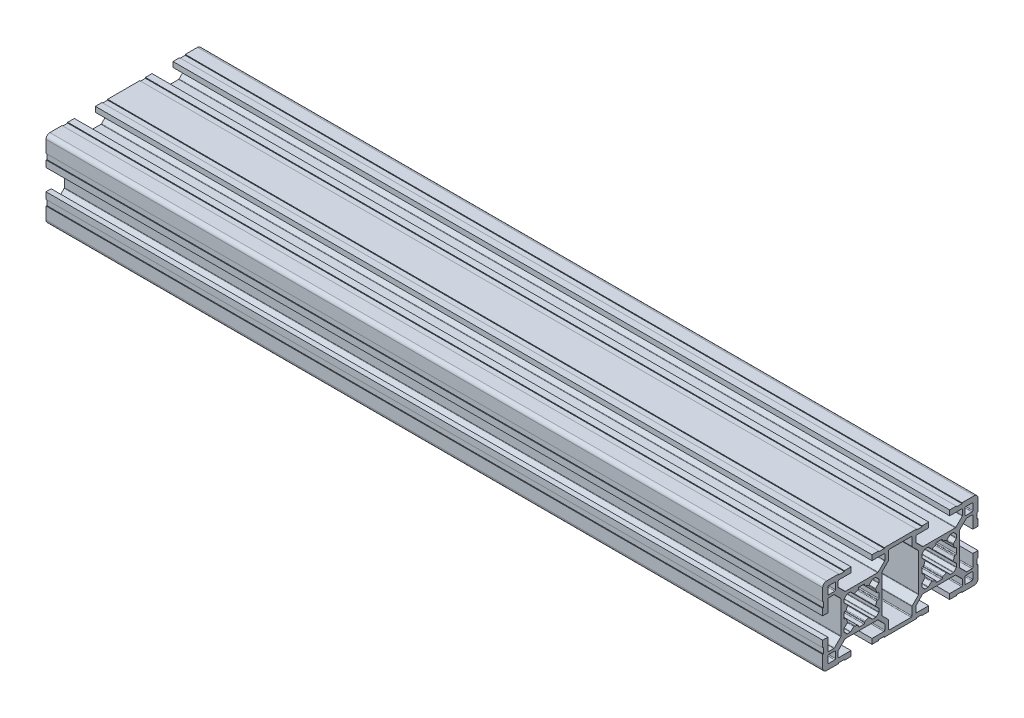
from build123d import *

# Parameters (mm, degrees)
RETANGULAR_PF30_02_PERFIL_3060_B_SICO_DEPTH = 300


with BuildPart() as part:
    # Sketch11 → Retangular PF30-02 - PERFIL 3060 BÁSICO(1) (new body)
    with BuildSketch(Plane.YZ.offset(-150)):
        with BuildLine():
            Line((-10.467761979, 23.914900409), (-7.987862303, 21.435000909))
            ThreePointArc((-7.987862303, 21.435000909), (-7.922830472, 21.337673902), (-7.89999433, 21.222868867))
            Line((-7.89999433, 21.222868867), (-7.89999433, 8.78267257))
            ThreePointArc((-7.89999433, 8.78267257), (-7.922830472, 8.667867535), (-7.987862303, 8.570540528))
            Line((-7.987862303, 8.570540528), (-10.467761979, 6.090641028))
            ThreePointArc((-10.467761979, 6.090641028), (-10.565088981, 6.025609208), (-10.679894006, 6.00277307))
            Line((-10.679894006, 6.00277307), (-12.699995366, 6.00277307))
            ThreePointArc((-12.699995366, 6.00277307), (-12.9121274, 6.090641035), (-12.999995366, 6.30277307))
            Line((-12.999995366, 6.30277307), (-12.999995366, 10.952772018))
            Line((-12.999995366, 10.952772018), (-14.999995923, 10.952772018))
            Line((-14.999995923, 10.952772018), (-14.999995923, 8.402773901))
            Line((-14.999995923, 8.402773901), (-14.699995922, 8.402773901))
            Line((-14.699995922, 8.402773901), (-14.699995922, 6.2027739))
            Line((-14.699995922, 6.2027739), (-14.999995923, 6.2027739))
            Line((-14.999995923, 6.2027739), (-14.999995923, -6.197224309))
            Line((-14.999995923, -6.197224309), (-14.699995922, -6.197224309))
            Line((-14.699995922, -6.197224309), (-14.699995922, -8.397224309))
            Line((-14.699995922, -8.397224309), (-14.999995923, -8.397224309))
            Line((-14.999995923, -8.397224309), (-14.999995923, -10.947222427))
            Line((-14.999995923, -10.947222427), (-12.999995366, -10.947222427))
            Line((-12.999995366, -10.947222427), (-12.999995366, -6.297223478))
            ThreePointArc((-12.999995366, -6.297223478), (-12.9121274, -6.085091444), (-12.699995366, -5.997223478))
            Line((-12.699995366, -5.997223478), (-10.679894006, -5.997223478))
            ThreePointArc((-10.679894006, -5.997223478), (-10.565088981, -6.020059616), (-10.467761979, -6.085091436))
            Line((-10.467761979, -6.085091436), (-7.987862303, -8.564990936))
            ThreePointArc((-7.987862303, -8.564990936), (-7.922830472, -8.662317943), (-7.89999433, -8.777122978))
            Line((-7.89999433, -8.777122978), (-7.89999433, -21.217319276))
            ThreePointArc((-7.89999433, -21.217319276), (-7.922830472, -21.33212431), (-7.987862303, -21.429451318))
            Line((-7.987862303, -21.429451318), (-10.467761979, -23.909350818))
            ThreePointArc((-10.467761979, -23.909350818), (-10.565088981, -23.974382637), (-10.679894006, -23.997218776))
            Line((-10.679894006, -23.997218776), (-12.699995366, -23.997218776))
            ThreePointArc((-12.699995366, -23.997218776), (-12.9121274, -23.90935081), (-12.999995366, -23.697218776))
            Line((-12.999995366, -23.697218776), (-12.999995366, -19.047219827))
            Line((-12.999995366, -19.047219827), (-14.999995923, -19.047219827))
            Line((-14.999995923, -19.047219827), (-14.999995923, -21.597217945))
            Line((-14.999995923, -21.597217945), (-14.699995922, -21.597217945))
            Line((-14.699995922, -21.597217945), (-14.699995922, -23.797217945))
            Line((-14.699995922, -23.797217945), (-14.999995923, -23.797217945))
            Line((-14.999995923, -23.797217945), (-14.999995923, -28.497216952))
            ThreePointArc((-14.999995923, -28.497216952), (-14.560656066, -29.557877193), (-13.499995825, -29.997217049))
            Line((-13.499995825, -29.997217049), (-8.799996802, -29.997217049))
            Line((-8.799996802, -29.997217049), (-8.799996802, -29.697217049))
            Line((-8.799996802, -29.697217049), (-6.599996802, -29.697217049))
            Line((-6.599996802, -29.697217049), (-6.599996802, -29.99721705))
            Line((-6.599996802, -29.99721705), (-4.0499987, -29.99721705))
            Line((-4.0499987, -29.99721705), (-4.0499987, -27.997216493))
            Line((-4.0499987, -27.997216493), (-8.699997649, -27.997216493))
            ThreePointArc((-8.699997649, -27.997216493), (-8.912129683, -27.909348527), (-8.999997649, -27.697216493))
            Line((-8.999997649, -27.697216493), (-8.999997649, -25.677115133))
            ThreePointArc((-8.999997649, -25.677115133), (-8.977161511, -25.562310108), (-8.912129691, -25.464983106))
            Line((-8.912129691, -25.464983106), (-6.432230191, -22.98508343))
            ThreePointArc((-6.432230191, -22.98508343), (-6.334903184, -22.920051599), (-6.220098149, -22.897215457))
            Line((-6.220098149, -22.897215457), (6.220098149, -22.897215457))
            ThreePointArc((6.220098149, -22.897215457), (6.334903184, -22.920051599), (6.432230191, -22.98508343))
            Line((6.432230191, -22.98508343), (8.912129691, -25.464983106))
            ThreePointArc((8.912129691, -25.464983106), (8.977161511, -25.562310108), (8.999997649, -25.677115133))
            Line((8.999997649, -25.677115133), (8.999997649, -27.697216493))
            ThreePointArc((8.999997649, -27.697216493), (8.912129683, -27.909348527), (8.699997649, -27.997216493))
            Line((8.699997649, -27.997216493), (4.0499987, -27.997216493))
            Line((4.0499987, -27.997216493), (4.0499987, -29.99721705))
            Line((4.0499987, -29.99721705), (6.599996802, -29.99721705))
            Line((6.599996802, -29.99721705), (6.599996802, -29.697217049))
            Line((6.599996802, -29.697217049), (8.799996802, -29.697217049))
            Line((8.799996802, -29.697217049), (8.799996802, -29.997217049))
            Line((8.799996802, -29.997217049), (13.499995825, -29.997217049))
            ThreePointArc((13.499995825, -29.997217049), (14.560656066, -29.557877193), (14.999995923, -28.497216952))
            Line((14.999995923, -28.497216952), (14.999995923, -23.797217945))
            Line((14.999995923, -23.797217945), (14.699995922, -23.797217945))
            Line((14.699995922, -23.797217945), (14.699995922, -21.597217945))
            Line((14.699995922, -21.597217945), (14.999995923, -21.597217945))
            Line((14.999995923, -21.597217945), (14.999995923, -19.047219827))
            Line((14.999995923, -19.047219827), (12.999995366, -19.047219827))
            Line((12.999995366, -19.047219827), (12.999995366, -23.697218776))
            ThreePointArc((12.999995366, -23.697218776), (12.9121274, -23.90935081), (12.699995366, -23.997218776))
            Line((12.699995366, -23.997218776), (10.679894006, -23.997218776))
            ThreePointArc((10.679894006, -23.997218776), (10.565088981, -23.974382637), (10.467761979, -23.909350818))
            Line((10.467761979, -23.909350818), (7.987862303, -21.429451318))
            ThreePointArc((7.987862303, -21.429451318), (7.922830472, -21.33212431), (7.89999433, -21.217319276))
            Line((7.89999433, -21.217319276), (7.89999433, -8.777122978))
            ThreePointArc((7.89999433, -8.777122978), (7.922830472, -8.662317943), (7.987862303, -8.564990936))
            Line((7.987862303, -8.564990936), (10.467761979, -6.085091436))
            ThreePointArc((10.467761979, -6.085091436), (10.565088981, -6.020059616), (10.679894006, -5.997223478))
            Line((10.679894006, -5.997223478), (12.699995366, -5.997223478))
            ThreePointArc((12.699995366, -5.997223478), (12.9121274, -6.085091444), (12.999995366, -6.297223478))
            Line((12.999995366, -6.297223478), (12.999995366, -10.947222427))
            Line((12.999995366, -10.947222427), (14.999995923, -10.947222427))
            Line((14.999995923, -10.947222427), (14.999995923, -8.397224309))
            Line((14.999995923, -8.397224309), (14.699995922, -8.397224309))
            Line((14.699995922, -8.397224309), (14.699995922, -6.197224309))
            Line((14.699995922, -6.197224309), (14.999995923, -6.197224309))
            Line((14.999995923, -6.197224309), (14.999995923, 6.2027739))
            Line((14.999995923, 6.2027739), (14.699995922, 6.2027739))
            Line((14.699995922, 6.2027739), (14.699995922, 8.402773901))
            Line((14.699995922, 8.402773901), (14.999995923, 8.402773901))
            Line((14.999995923, 8.402773901), (14.999995923, 10.952772018))
            Line((14.999995923, 10.952772018), (12.999995366, 10.952772018))
            Line((12.999995366, 10.952772018), (12.999995366, 6.30277307))
            ThreePointArc((12.999995366, 6.30277307), (12.9121274, 6.090641035), (12.699995366, 6.00277307))
            Line((12.699995366, 6.00277307), (10.679894006, 6.00277307))
            ThreePointArc((10.679894006, 6.00277307), (10.565088981, 6.025609208), (10.467761979, 6.090641028))
            Line((10.467761979, 6.090641028), (7.987862303, 8.570540528))
            ThreePointArc((7.987862303, 8.570540528), (7.922830472, 8.667867535), (7.89999433, 8.78267257))
            Line((7.89999433, 8.78267257), (7.89999433, 21.222868867))
            ThreePointArc((7.89999433, 21.222868867), (7.922830472, 21.337673902), (7.987862303, 21.435000909))
            Line((7.987862303, 21.435000909), (10.467761979, 23.914900409))
            ThreePointArc((10.467761979, 23.914900409), (10.565088981, 23.979932229), (10.679894006, 24.002768367))
            Line((10.679894006, 24.002768367), (12.699995366, 24.002768367))
            ThreePointArc((12.699995366, 24.002768367), (12.9121274, 23.914900401), (12.999995366, 23.702768367))
            Line((12.999995366, 23.702768367), (12.999995366, 19.052769418))
            Line((12.999995366, 19.052769418), (14.999995923, 19.052769418))
            Line((14.999995923, 19.052769418), (14.999995923, 21.602767536))
            Line((14.999995923, 21.602767536), (14.699995922, 21.602767536))
            Line((14.699995922, 21.602767536), (14.699995922, 23.802767536))
            Line((14.699995922, 23.802767536), (14.999995923, 23.802767536))
            Line((14.999995923, 23.802767536), (14.999995923, 28.502766544))
            ThreePointArc((14.999995923, 28.502766544), (14.560656066, 29.563426784), (13.499995825, 30.002766641))
            Line((13.499995825, 30.002766641), (8.799996802, 30.002766641))
            Line((8.799996802, 30.002766641), (8.799996802, 29.702766641))
            Line((8.799996802, 29.702766641), (6.599996802, 29.702766641))
            Line((6.599996802, 29.702766641), (6.599996802, 30.002766641))
            Line((6.599996802, 30.002766641), (4.0499987, 30.002766641))
            Line((4.0499987, 30.002766641), (4.0499987, 28.002766084))
            Line((4.0499987, 28.002766084), (8.699997649, 28.002766084))
            ThreePointArc((8.699997649, 28.002766084), (8.912129683, 27.914898119), (8.999997649, 27.702766084))
            Line((8.999997649, 27.702766084), (8.999997649, 25.682664725))
            ThreePointArc((8.999997649, 25.682664725), (8.977161511, 25.5678597), (8.912129691, 25.470532698))
            Line((8.912129691, 25.470532698), (6.432230191, 22.990633021))
            ThreePointArc((6.432230191, 22.990633021), (6.334903184, 22.92560119), (6.220098149, 22.902765048))
            Line((6.220098149, 22.902765048), (-6.220098149, 22.902765048))
            ThreePointArc((-6.220098149, 22.902765048), (-6.334903184, 22.92560119), (-6.432230191, 22.990633021))
            Line((-6.432230191, 22.990633021), (-8.912129691, 25.470532698))
            ThreePointArc((-8.912129691, 25.470532698), (-8.977161511, 25.5678597), (-8.999997649, 25.682664725))
            Line((-8.999997649, 25.682664725), (-8.999997649, 27.702766084))
            ThreePointArc((-8.999997649, 27.702766084), (-8.912129683, 27.914898119), (-8.699997649, 28.002766084))
            Line((-8.699997649, 28.002766084), (-4.0499987, 28.002766084))
            Line((-4.0499987, 28.002766084), (-4.0499987, 30.002766641))
            Line((-4.0499987, 30.002766641), (-6.599996802, 30.002766641))
            Line((-6.599996802, 30.002766641), (-6.599996802, 29.702766641))
            Line((-6.599996802, 29.702766641), (-8.799996802, 29.702766641))
            Line((-8.799996802, 29.702766641), (-8.799996802, 30.002766641))
            Line((-8.799996802, 30.002766641), (-13.499995825, 30.002766641))
            ThreePointArc((-13.499995825, 30.002766641), (-14.560656066, 29.563426784), (-14.999995923, 28.502766544))
            Line((-14.999995923, 28.502766544), (-14.999995923, 23.802767536))
            Line((-14.999995923, 23.802767536), (-14.699995922, 23.802767536))
            Line((-14.699995922, 23.802767536), (-14.699995922, 21.602767536))
            Line((-14.699995922, 21.602767536), (-14.999995923, 21.602767536))
            Line((-14.999995923, 21.602767536), (-14.999995923, 19.052769418))
            Line((-14.999995923, 19.052769418), (-12.999995366, 19.052769418))
            Line((-12.999995366, 19.052769418), (-12.999995366, 23.702768367))
            ThreePointArc((-12.999995366, 23.702768367), (-12.9121274, 23.914900401), (-12.699995366, 24.002768367))
            Line((-12.699995366, 24.002768367), (-10.679894006, 24.002768367))
            ThreePointArc((-10.679894006, 24.002768367), (-10.565088981, 23.979932229), (-10.467761979, 23.914900409))
        make_face()
        with BuildLine():
            Line((-9.846446918, -4.590642769), (-7.422182, -7.014907859))
            ThreePointArc((-7.422182, -7.014907859), (-7.324854993, -7.07993969), (-7.210049959, -7.102775832))
            Line((-7.210049959, -7.102775832), (7.210049959, -7.102775832))
            ThreePointArc((7.210049959, -7.102775832), (7.324854993, -7.07993969), (7.422182, -7.014907859))
            Line((7.422182, -7.014907859), (9.846446918, -4.590642769))
            ThreePointArc((9.846446918, -4.590642769), (9.943773925, -4.525610938), (10.05857896, -4.502774796))
            Line((10.05857896, -4.502774796), (13.2, -4.502774796))
            ThreePointArc((13.2, -4.502774796), (13.412132034, -4.41490683), (13.5, -4.202774796))
            Line((13.5, -4.202774796), (13.5, 4.197225204))
            ThreePointArc((13.5, 4.197225204), (13.412132034, 4.409357239), (13.2, 4.497225204))
            Line((13.2, 4.497225204), (10.05857896, 4.497225204))
            ThreePointArc((10.05857896, 4.497225204), (9.943773925, 4.520061347), (9.846446918, 4.585093178))
            Line((9.846446918, 4.585093178), (7.422182001, 7.009358267))
            ThreePointArc((7.422182001, 7.009358267), (7.324854993, 7.074390098), (7.210049959, 7.097226241))
            Line((7.210049959, 7.097226241), (-7.210049958, 7.097226241))
            ThreePointArc((-7.210049958, 7.097226241), (-7.324854993, 7.074390098), (-7.422182, 7.009358267))
            Line((-7.422182, 7.009358267), (-9.846446917, 4.585093178))
            ThreePointArc((-9.846446917, 4.585093178), (-9.943773925, 4.520061347), (-10.058578959, 4.497225204))
            Line((-10.058578959, 4.497225204), (-13.2, 4.497225204))
            ThreePointArc((-13.2, 4.497225204), (-13.412132034, 4.409357239), (-13.5, 4.197225204))
            Line((-13.5, 4.197225204), (-13.5, -4.202774796))
            ThreePointArc((-13.5, -4.202774796), (-13.412132034, -4.41490683), (-13.2, -4.502774796))
            Line((-13.2, -4.502774796), (-10.05857896, -4.502774796))
            ThreePointArc((-10.05857896, -4.502774796), (-9.943773925, -4.525610938), (-9.846446918, -4.590642769))
        make_face(mode=Mode.SUBTRACT)
        with BuildLine():
            Line((-6.69999433, 15.952769357), (-6.69999433, 14.05277208))
            ThreePointArc((-6.69999433, 14.05277208), (-6.612125883, 13.840639564), (-6.399992969, 13.75277208))
            Line((-6.399992969, 13.75277208), (-6.157923707, 13.752773178))
            ThreePointArc((-6.157923707, 13.752773178), (-5.973489249, 13.689383475), (-5.866996881, 13.526001408))
            ThreePointArc((-5.866996881, 13.526001408), (-5.679815238, 12.918976375), (-5.430017698, 12.334923683))
            ThreePointArc((-5.430017698, 12.334923683), (-5.403317864, 12.15354701), (-5.487142739, 11.990501713))
            Line((-5.487142739, 11.990501713), (-6.612126364, 10.865518089))
            ThreePointArc((-6.612126364, 10.865518089), (-6.677158189, 10.768191084), (-6.69999433, 10.653386054))
            Line((-6.69999433, 10.653386054), (-6.69999433, 9.563210784))
            ThreePointArc((-6.69999433, 9.563210784), (-6.677158176, 9.448405723), (-6.612126315, 9.351078701))
            Line((-6.612126315, 9.351078701), (-6.131909052, 8.870861658))
            Line((-6.131909052, 8.870861658), (-5.651692017, 8.390644403))
            ThreePointArc((-5.651692017, 8.390644403), (-5.554364996, 8.325612542), (-5.439559934, 8.302776389))
            Line((-5.439559934, 8.302776389), (-4.349384664, 8.302776389))
            ThreePointArc((-4.349384664, 8.302776389), (-4.234579634, 8.325612529), (-4.13725263, 8.390644354))
            Line((-4.13725263, 8.390644354), (-3.012269005, 9.515627979))
            ThreePointArc((-3.012269005, 9.515627979), (-2.849223708, 9.599452854), (-2.667847035, 9.572753021))
            ThreePointArc((-2.667847035, 9.572753021), (-2.083794343, 9.322955481), (-1.476769311, 9.135773837))
            ThreePointArc((-1.476769311, 9.135773837), (-1.313387244, 9.02928147), (-1.249997541, 8.844847011))
            Line((-1.249997541, 8.844847011), (-1.249998639, 8.60277775))
            ThreePointArc((-1.249998639, 8.60277775), (-1.162131155, 8.390644836), (-0.949998639, 8.302776389))
            Line((-0.949998639, 8.302776389), (0.949998639, 8.302776389))
            ThreePointArc((0.949998639, 8.302776389), (1.162131155, 8.390644836), (1.249998639, 8.60277775))
            Line((1.249998639, 8.60277775), (1.249997541, 8.844847011))
            ThreePointArc((1.249997541, 8.844847011), (1.313387244, 9.02928147), (1.476769311, 9.135773837))
            ThreePointArc((1.476769311, 9.135773837), (2.083794343, 9.322955481), (2.667847035, 9.572753021))
            ThreePointArc((2.667847035, 9.572753021), (2.849223708, 9.599452854), (3.012269005, 9.515627979))
            Line((3.012269005, 9.515627979), (4.13725263, 8.390644354))
            ThreePointArc((4.13725263, 8.390644354), (4.234579634, 8.325612529), (4.349384664, 8.302776389))
            Line((4.349384664, 8.302776389), (5.439559934, 8.302776389))
            ThreePointArc((5.439559934, 8.302776389), (5.554364996, 8.325612542), (5.651692017, 8.390644403))
            Line((5.651692017, 8.390644403), (6.131909052, 8.870861658))
            Line((6.131909052, 8.870861658), (6.612126315, 9.351078701))
            ThreePointArc((6.612126315, 9.351078701), (6.677158176, 9.448405723), (6.69999433, 9.563210784))
            Line((6.69999433, 9.563210784), (6.69999433, 10.653386054))
            ThreePointArc((6.69999433, 10.653386054), (6.677158189, 10.768191084), (6.612126364, 10.865518089))
            Line((6.612126364, 10.865518089), (5.487142739, 11.990501713))
            ThreePointArc((5.487142739, 11.990501713), (5.403317864, 12.15354701), (5.430017698, 12.334923683))
            ThreePointArc((5.430017698, 12.334923683), (5.679815238, 12.918976375), (5.866996881, 13.526001408))
            ThreePointArc((5.866996881, 13.526001408), (5.973489249, 13.689383475), (6.157923707, 13.752773178))
            Line((6.157923707, 13.752773178), (6.399992969, 13.75277208))
            ThreePointArc((6.399992969, 13.75277208), (6.612125883, 13.840639564), (6.69999433, 14.05277208))
            Line((6.69999433, 14.05277208), (6.69999433, 15.952769357))
            ThreePointArc((6.69999433, 15.952769357), (6.612125883, 16.164901872), (6.399992969, 16.252769357))
            Line((6.399992969, 16.252769357), (6.157923707, 16.252768259))
            ThreePointArc((6.157923707, 16.252768259), (5.973489249, 16.316157962), (5.866996881, 16.479540029))
            ThreePointArc((5.866996881, 16.479540029), (5.679815238, 17.086565061), (5.430017698, 17.670617753))
            ThreePointArc((5.430017698, 17.670617753), (5.403317864, 17.851994426), (5.487142739, 18.015039723))
            Line((5.487142739, 18.015039723), (6.612126364, 19.140023348))
            ThreePointArc((6.612126364, 19.140023348), (6.677158189, 19.237350353), (6.69999433, 19.352155382))
            Line((6.69999433, 19.352155382), (6.69999433, 20.442330653))
            ThreePointArc((6.69999433, 20.442330653), (6.677158176, 20.557135714), (6.612126315, 20.654462736))
            Line((6.612126315, 20.654462736), (6.131909052, 21.134679779))
            Line((6.131909052, 21.134679779), (5.651692017, 21.614897034))
            ThreePointArc((5.651692017, 21.614897034), (5.554364996, 21.679928895), (5.439559934, 21.702765048))
            Line((5.439559934, 21.702765048), (4.349384664, 21.702765048))
            ThreePointArc((4.349384664, 21.702765048), (4.234579634, 21.679928908), (4.13725263, 21.614897082))
            Line((4.13725263, 21.614897082), (3.012269005, 20.489913458))
            ThreePointArc((3.012269005, 20.489913458), (2.849223708, 20.406088583), (2.667847035, 20.432788416))
            ThreePointArc((2.667847035, 20.432788416), (2.083794343, 20.682585956), (1.476769311, 20.869767599))
            ThreePointArc((1.476769311, 20.869767599), (1.313387244, 20.976259967), (1.249997541, 21.160694426))
            Line((1.249997541, 21.160694426), (1.249998639, 21.402763687))
            ThreePointArc((1.249998639, 21.402763687), (1.162131155, 21.614896601), (0.949998639, 21.702765048))
            Line((0.949998639, 21.702765048), (-0.949998639, 21.702765048))
            ThreePointArc((-0.949998639, 21.702765048), (-1.162131155, 21.614896601), (-1.249998639, 21.402763687))
            Line((-1.249998639, 21.402763687), (-1.249997541, 21.160694426))
            ThreePointArc((-1.249997541, 21.160694426), (-1.313387244, 20.976259967), (-1.476769311, 20.869767599))
            ThreePointArc((-1.476769311, 20.869767599), (-2.083794343, 20.682585956), (-2.667847035, 20.432788416))
            ThreePointArc((-2.667847035, 20.432788416), (-2.849223708, 20.406088583), (-3.012269005, 20.489913458))
            Line((-3.012269005, 20.489913458), (-4.13725263, 21.614897082))
            ThreePointArc((-4.13725263, 21.614897082), (-4.234579634, 21.679928908), (-4.349384664, 21.702765048))
            Line((-4.349384664, 21.702765048), (-5.439559934, 21.702765048))
            ThreePointArc((-5.439559934, 21.702765048), (-5.554364996, 21.679928895), (-5.651692017, 21.614897034))
            Line((-5.651692017, 21.614897034), (-6.131909052, 21.134679779))
            Line((-6.131909052, 21.134679779), (-6.612126315, 20.654462736))
            ThreePointArc((-6.612126315, 20.654462736), (-6.677158176, 20.557135714), (-6.69999433, 20.442330653))
            Line((-6.69999433, 20.442330653), (-6.69999433, 19.352155382))
            ThreePointArc((-6.69999433, 19.352155382), (-6.677158189, 19.237350353), (-6.612126364, 19.140023348))
            Line((-6.612126364, 19.140023348), (-5.487142739, 18.015039723))
            ThreePointArc((-5.487142739, 18.015039723), (-5.403317864, 17.851994426), (-5.430017698, 17.670617753))
            ThreePointArc((-5.430017698, 17.670617753), (-5.679815238, 17.086565061), (-5.866996881, 16.479540029))
            ThreePointArc((-5.866996881, 16.479540029), (-5.973489249, 16.316157962), (-6.157923707, 16.252768259))
            Line((-6.157923707, 16.252768259), (-6.399992969, 16.252769357))
            ThreePointArc((-6.399992969, 16.252769357), (-6.612125883, 16.164901872), (-6.69999433, 15.952769357))
        make_face(mode=Mode.SUBTRACT)
        with BuildLine():
            Line((-12.999997649, 25.302766084), (-12.999997649, 27.702766084))
            ThreePointArc((-12.999997649, 27.702766084), (-12.912129683, 27.914898119), (-12.699997649, 28.002766084))
            Line((-12.699997649, 28.002766084), (-10.299997649, 28.002766084))
            ThreePointArc((-10.299997649, 28.002766084), (-10.087865615, 27.914898119), (-9.999997649, 27.702766084))
            Line((-9.999997649, 27.702766084), (-9.999997649, 25.302766084))
            ThreePointArc((-9.999997649, 25.302766084), (-10.087865615, 25.09063405), (-10.299997649, 25.002766084))
            Line((-10.299997649, 25.002766084), (-12.699997649, 25.002766084))
            ThreePointArc((-12.699997649, 25.002766084), (-12.912129683, 25.09063405), (-12.999997649, 25.302766084))
        make_face(mode=Mode.SUBTRACT)
        with BuildLine():
            Line((10.299997649, 25.002766084), (12.699997649, 25.002766084))
            ThreePointArc((12.699997649, 25.002766084), (12.912129683, 25.09063405), (12.999997649, 25.302766084))
            Line((12.999997649, 25.302766084), (12.999997649, 27.702766084))
            ThreePointArc((12.999997649, 27.702766084), (12.912129683, 27.914898119), (12.699997649, 28.002766084))
            Line((12.699997649, 28.002766084), (10.299997649, 28.002766084))
            ThreePointArc((10.299997649, 28.002766084), (10.087865615, 27.914898119), (9.999997649, 27.702766084))
            Line((9.999997649, 27.702766084), (9.999997649, 25.302766084))
            ThreePointArc((9.999997649, 25.302766084), (10.087865615, 25.09063405), (10.299997649, 25.002766084))
        make_face(mode=Mode.SUBTRACT)
        with BuildLine():
            Line((-6.157923707, -13.747223586), (-6.399992969, -13.747222488))
            ThreePointArc((-6.399992969, -13.747222488), (-6.612125883, -13.835089973), (-6.69999433, -14.047222488))
            Line((-6.69999433, -14.047222488), (-6.69999433, -15.947219765))
            ThreePointArc((-6.69999433, -15.947219765), (-6.612125883, -16.159352281), (-6.399992969, -16.247219765))
            Line((-6.399992969, -16.247219765), (-6.157923707, -16.247218667))
            ThreePointArc((-6.157923707, -16.247218667), (-5.973489249, -16.310608371), (-5.866996881, -16.473990437))
            ThreePointArc((-5.866996881, -16.473990437), (-5.679815238, -17.08101547), (-5.430017698, -17.665068162))
            ThreePointArc((-5.430017698, -17.665068162), (-5.403317864, -17.846444835), (-5.487142739, -18.009490132))
            Line((-5.487142739, -18.009490132), (-6.612126364, -19.134473757))
            ThreePointArc((-6.612126364, -19.134473757), (-6.677158189, -19.231800761), (-6.69999433, -19.346605791))
            Line((-6.69999433, -19.346605791), (-6.69999433, -20.436781061))
            ThreePointArc((-6.69999433, -20.436781061), (-6.677158176, -20.551586123), (-6.612126315, -20.648913144))
            Line((-6.612126315, -20.648913144), (-6.131909052, -21.129130187))
            Line((-6.131909052, -21.129130187), (-5.651692017, -21.609347442))
            ThreePointArc((-5.651692017, -21.609347442), (-5.554364996, -21.674379303), (-5.439559934, -21.697215457))
            Line((-5.439559934, -21.697215457), (-4.349384664, -21.697215457))
            ThreePointArc((-4.349384664, -21.697215457), (-4.234579634, -21.674379316), (-4.13725263, -21.609347491))
            Line((-4.13725263, -21.609347491), (-3.012269005, -20.484363866))
            ThreePointArc((-3.012269005, -20.484363866), (-2.849223708, -20.400538991), (-2.667847035, -20.427238825))
            ThreePointArc((-2.667847035, -20.427238825), (-2.083794343, -20.677036365), (-1.476769311, -20.864218008))
            ThreePointArc((-1.476769311, -20.864218008), (-1.313387244, -20.970710376), (-1.249997541, -21.155144834))
            Line((-1.249997541, -21.155144834), (-1.249998639, -21.397214096))
            ThreePointArc((-1.249998639, -21.397214096), (-1.162131155, -21.60934701), (-0.949998639, -21.697215457))
            Line((-0.949998639, -21.697215457), (0.949998639, -21.697215457))
            ThreePointArc((0.949998639, -21.697215457), (1.162131155, -21.60934701), (1.249998639, -21.397214096))
            Line((1.249998639, -21.397214096), (1.249997541, -21.155144834))
            ThreePointArc((1.249997541, -21.155144834), (1.313387244, -20.970710376), (1.476769311, -20.864218008))
            ThreePointArc((1.476769311, -20.864218008), (2.083794343, -20.677036365), (2.667847035, -20.427238825))
            ThreePointArc((2.667847035, -20.427238825), (2.849223708, -20.400538991), (3.012269005, -20.484363866))
            Line((3.012269005, -20.484363866), (4.13725263, -21.609347491))
            ThreePointArc((4.13725263, -21.609347491), (4.234579634, -21.674379316), (4.349384664, -21.697215457))
            Line((4.349384664, -21.697215457), (5.439559934, -21.697215457))
            ThreePointArc((5.439559934, -21.697215457), (5.554364996, -21.674379303), (5.651692017, -21.609347442))
            Line((5.651692017, -21.609347442), (6.131909052, -21.129130187))
            Line((6.131909052, -21.129130187), (6.612126315, -20.648913144))
            ThreePointArc((6.612126315, -20.648913144), (6.677158176, -20.551586123), (6.69999433, -20.436781061))
            Line((6.69999433, -20.436781061), (6.69999433, -19.346605791))
            ThreePointArc((6.69999433, -19.346605791), (6.677158189, -19.231800761), (6.612126364, -19.134473757))
            Line((6.612126364, -19.134473757), (5.487142739, -18.009490132))
            ThreePointArc((5.487142739, -18.009490132), (5.403317864, -17.846444835), (5.430017698, -17.665068162))
            ThreePointArc((5.430017698, -17.665068162), (5.679815238, -17.08101547), (5.866996881, -16.473990437))
            ThreePointArc((5.866996881, -16.473990437), (5.973489249, -16.310608371), (6.157923707, -16.247218667))
            Line((6.157923707, -16.247218667), (6.399992969, -16.247219765))
            ThreePointArc((6.399992969, -16.247219765), (6.612125883, -16.159352281), (6.69999433, -15.947219765))
            Line((6.69999433, -15.947219765), (6.69999433, -14.047222488))
            ThreePointArc((6.69999433, -14.047222488), (6.612125883, -13.835089973), (6.399992969, -13.747222488))
            Line((6.399992969, -13.747222488), (6.157923707, -13.747223586))
            ThreePointArc((6.157923707, -13.747223586), (5.973489249, -13.683833883), (5.866996881, -13.520451817))
            ThreePointArc((5.866996881, -13.520451817), (5.679815238, -12.913426784), (5.430017698, -12.329374092))
            ThreePointArc((5.430017698, -12.329374092), (5.403317864, -12.147997419), (5.487142739, -11.984952122))
            Line((5.487142739, -11.984952122), (6.612126364, -10.859968497))
            ThreePointArc((6.612126364, -10.859968497), (6.677158189, -10.762641493), (6.69999433, -10.647836463))
            Line((6.69999433, -10.647836463), (6.69999433, -9.557661193))
            ThreePointArc((6.69999433, -9.557661193), (6.677158176, -9.442856131), (6.612126315, -9.34552911))
            Line((6.612126315, -9.34552911), (6.131909052, -8.865312067))
            Line((6.131909052, -8.865312067), (5.651692017, -8.385094811))
            ThreePointArc((5.651692017, -8.385094811), (5.554364996, -8.320062951), (5.439559934, -8.297226797))
            Line((5.439559934, -8.297226797), (4.349384664, -8.297226797))
            ThreePointArc((4.349384664, -8.297226797), (4.234579634, -8.320062937), (4.13725263, -8.385094763))
            Line((4.13725263, -8.385094763), (3.012269005, -9.510078388))
            ThreePointArc((3.012269005, -9.510078388), (2.849223708, -9.593903263), (2.667847035, -9.567203429))
            ThreePointArc((2.667847035, -9.567203429), (2.083794343, -9.317405889), (1.476769311, -9.130224246))
            ThreePointArc((1.476769311, -9.130224246), (1.313387244, -9.023731878), (1.249997541, -8.83929742))
            Line((1.249997541, -8.83929742), (1.249998639, -8.597228158))
            ThreePointArc((1.249998639, -8.597228158), (1.162131155, -8.385095244), (0.949998639, -8.297226797))
            Line((0.949998639, -8.297226797), (-0.949998639, -8.297226797))
            ThreePointArc((-0.949998639, -8.297226797), (-1.162131155, -8.385095244), (-1.249998639, -8.597228158))
            Line((-1.249998639, -8.597228158), (-1.249997541, -8.83929742))
            ThreePointArc((-1.249997541, -8.83929742), (-1.313387244, -9.023731878), (-1.476769311, -9.130224246))
            ThreePointArc((-1.476769311, -9.130224246), (-2.083794343, -9.317405889), (-2.667847035, -9.567203429))
            ThreePointArc((-2.667847035, -9.567203429), (-2.849223708, -9.593903263), (-3.012269005, -9.510078388))
            Line((-3.012269005, -9.510078388), (-4.13725263, -8.385094763))
            ThreePointArc((-4.13725263, -8.385094763), (-4.234579634, -8.320062937), (-4.349384664, -8.297226797))
            Line((-4.349384664, -8.297226797), (-5.439559934, -8.297226797))
            ThreePointArc((-5.439559934, -8.297226797), (-5.554364996, -8.320062951), (-5.651692017, -8.385094811))
            Line((-5.651692017, -8.385094811), (-6.131909052, -8.865312067))
            Line((-6.131909052, -8.865312067), (-6.612126315, -9.34552911))
            ThreePointArc((-6.612126315, -9.34552911), (-6.677158176, -9.442856131), (-6.69999433, -9.557661193))
            Line((-6.69999433, -9.557661193), (-6.69999433, -10.647836463))
            ThreePointArc((-6.69999433, -10.647836463), (-6.677158189, -10.762641493), (-6.612126364, -10.859968497))
            Line((-6.612126364, -10.859968497), (-5.487142739, -11.984952122))
            ThreePointArc((-5.487142739, -11.984952122), (-5.403317864, -12.147997419), (-5.430017698, -12.329374092))
            ThreePointArc((-5.430017698, -12.329374092), (-5.679815238, -12.913426784), (-5.866996881, -13.520451817))
            ThreePointArc((-5.866996881, -13.520451817), (-5.973489249, -13.683833883), (-6.157923707, -13.747223586))
        make_face(mode=Mode.SUBTRACT)
        with BuildLine():
            Line((-10.299997649, -24.997216493), (-12.699997649, -24.997216493))
            ThreePointArc((-12.699997649, -24.997216493), (-12.912129683, -25.085084458), (-12.999997649, -25.297216493))
            Line((-12.999997649, -25.297216493), (-12.999997649, -27.697216493))
            ThreePointArc((-12.999997649, -27.697216493), (-12.912129683, -27.909348527), (-12.699997649, -27.997216493))
            Line((-12.699997649, -27.997216493), (-10.299997649, -27.997216493))
            ThreePointArc((-10.299997649, -27.997216493), (-10.087865615, -27.909348527), (-9.999997649, -27.697216493))
            Line((-9.999997649, -27.697216493), (-9.999997649, -25.297216493))
            ThreePointArc((-9.999997649, -25.297216493), (-10.087865615, -25.085084458), (-10.299997649, -24.997216493))
        make_face(mode=Mode.SUBTRACT)
        with BuildLine():
            Line((12.999997649, -25.297216493), (12.999997649, -27.697216493))
            ThreePointArc((12.999997649, -27.697216493), (12.912129683, -27.909348527), (12.699997649, -27.997216493))
            Line((12.699997649, -27.997216493), (10.299997649, -27.997216493))
            ThreePointArc((10.299997649, -27.997216493), (10.087865615, -27.909348527), (9.999997649, -27.697216493))
            Line((9.999997649, -27.697216493), (9.999997649, -25.297216493))
            ThreePointArc((9.999997649, -25.297216493), (10.087865615, -25.085084458), (10.299997649, -24.997216493))
            Line((10.299997649, -24.997216493), (12.699997649, -24.997216493))
            ThreePointArc((12.699997649, -24.997216493), (12.912129683, -25.085084458), (12.999997649, -25.297216493))
        make_face(mode=Mode.SUBTRACT)
    extrude(amount=RETANGULAR_PF30_02_PERFIL_3060_B_SICO_DEPTH)


solid = part.part
